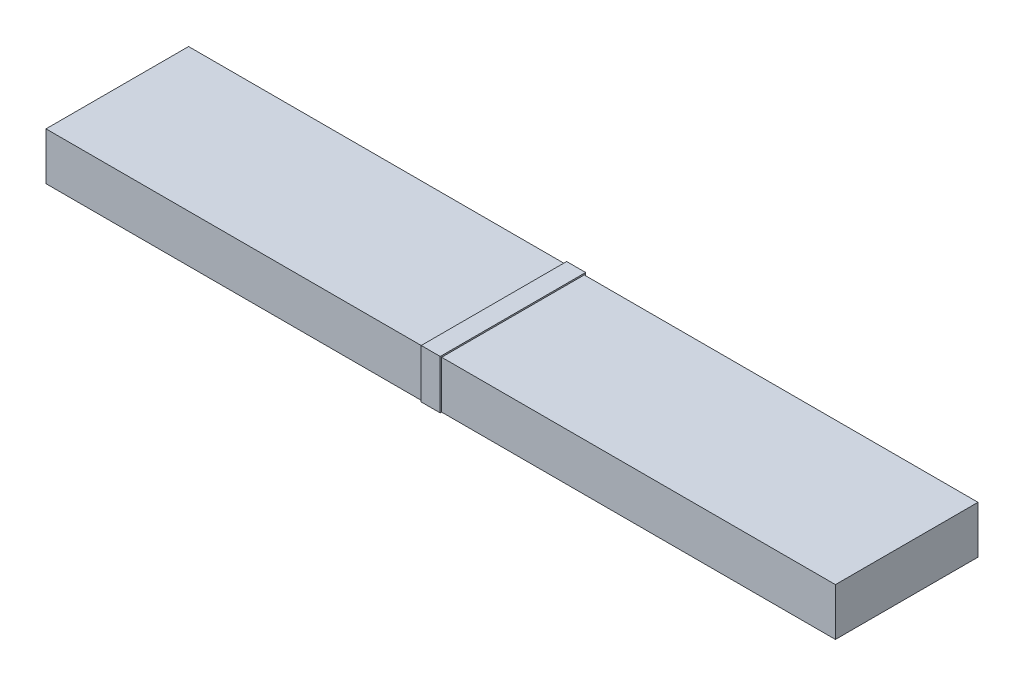
from build123d import *

# Parameters (mm, degrees)
BOSS_EXTRUDE1_DEPTH      = 150
BOSS_EXTRUDE1_DEPTH_BACK = 150
SKETCH1_W                = 1661
SKETCH1_H                = 100
BOSS_EXTRUDE2_DEPTH      = 2
BOSS_EXTRUDE2_DEPTH_BACK = 38


with BuildPart() as part:
    # Sketch1 → Boss-Extrude1 (new, two sides: drawn at the far end of the back side and taken through both)
    with BuildSketch(Plane.XY.offset(-BOSS_EXTRUDE1_DEPTH_BACK)):
        Rectangle(SKETCH1_W, SKETCH1_H)
    extrude(amount=BOSS_EXTRUDE1_DEPTH + BOSS_EXTRUDE1_DEPTH_BACK)


with BuildPart() as body_2:
    # Sketch2 → Boss-Extrude2 (new, two sides: drawn at the far end of the back side and taken through both)
    with BuildSketch(Plane(origin=(0, 0, 0), x_dir=(0, 0, -1), z_dir=(1, 0, 0)).offset(-BOSS_EXTRUDE2_DEPTH_BACK)):
        Polygon((-150, -50), (-150, 50), (150, 50), (150, -50), (153, -50), (153, 53), (-153, 53), (-153, -50), align=None)
    extrude(amount=BOSS_EXTRUDE2_DEPTH + BOSS_EXTRUDE2_DEPTH_BACK)


solid = Compound([part.part, body_2.part])
